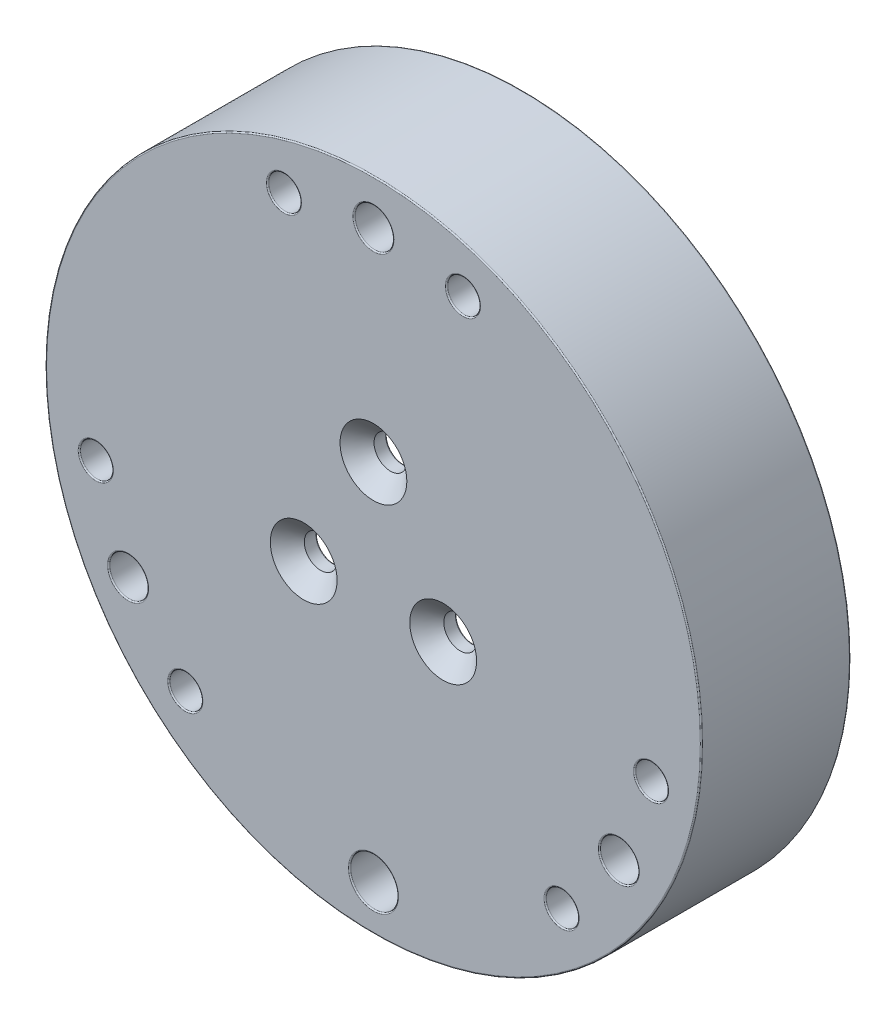
from build123d import *

# Parameters (mm, degrees)
CROQUIS1_R                                           = 55
CROQUIS1_R_2                                         = 52.5
SALIENTE_EXTRUIR1_DEPTH                              = 20
CROQUIS2_R                                           = 55
SALIENTE_EXTRUIR2_DEPTH                              = 5
REFRENTADO_PARA_TORNILLO_TAP_N_CON_CABEZ_D           = 5.5
REFRENTADO_PARA_TORNILLO_TAP_N_CON_CABEZ_CSINK_D     = 11.2
REFRENTADO_PARA_TORNILLO_TAP_N_CON_CABEZ_CSINK_ANGLE = 90
SALIENTE_EXTRUIR8_DEPTH                              = 10
CROQUIS12_R                                          = 3.25
CROQUIS12_R_2                                        = 4
CORTAR_EXTRUIR4_DEPTH                                = 10
CROQUIS16_R                                          = 2.75
CORTAR_EXTRUIR7_DEPTH                                = 5
REDONDEO1_R                                          = 0.2


with BuildPart() as part:
    # Croquis1 → Saliente-Extruir1 (new body)
    with BuildSketch(Plane.XY):
        Circle(CROQUIS1_R)
        Circle(CROQUIS1_R_2, mode=Mode.SUBTRACT)
    extrude(amount=SALIENTE_EXTRUIR1_DEPTH)

    # Croquis2 → Saliente-Extruir2 (add)
    with BuildSketch(Plane.XY.offset(20)):
        Circle(CROQUIS2_R)
    extrude(amount=SALIENTE_EXTRUIR2_DEPTH)

    # Refrentado para tornillo tapón con cabeza plana de clavija de M51 (through all)
    with Locations(Plane.XY.offset(25)):
        with Locations((0, 13.5), (-11.691342951, -6.75), (11.691342951, -6.75)):
            CounterSinkHole(REFRENTADO_PARA_TORNILLO_TAP_N_CON_CABEZ_D / 2, REFRENTADO_PARA_TORNILLO_TAP_N_CON_CABEZ_CSINK_D / 2, counter_sink_angle=REFRENTADO_PARA_TORNILLO_TAP_N_CON_CABEZ_CSINK_ANGLE)

    # Croquis10 → Saliente-Extruir8 (add)
    with BuildSketch(Plane(origin=(0, 0, 20), x_dir=(-1, 0, 0), z_dir=(0, 0, -1))):
        with BuildLine():
            Line((-3.5, 45), (-3.5, 51))
            ThreePointArc((-3.5, 51), (0, 54.5), (3.5, 51))
            Line((3.5, 51), (3.5, 45))
            ThreePointArc((3.5, 45), (0, 41.5), (-3.5, 45))
        make_face()
        with BuildLine():
            Line((40.72114317, -19.468911087), (45.917295593, -22.468911087))
            ThreePointArc((45.917295593, -22.468911087), (47.198384506, -27.25), (42.417295593, -28.531088913))
            Line((42.417295593, -28.531088913), (37.22114317, -25.531088913))
            ThreePointArc((37.22114317, -25.531088913), (35.940054257, -20.75), (40.72114317, -19.468911087))
        make_face()
        with BuildLine():
            Line((-37.22114317, -25.531088913), (-42.417295593, -28.531088913))
            ThreePointArc((-42.417295593, -28.531088913), (-47.198384506, -27.25), (-45.917295593, -22.468911087))
            Line((-45.917295593, -22.468911087), (-40.72114317, -19.468911087))
            ThreePointArc((-40.72114317, -19.468911087), (-35.940054257, -20.75), (-37.22114317, -25.531088913))
        make_face()
        with BuildLine():
            Line((-4.5, -50.030679936), (-4.5, -38.370856831))
            ThreePointArc((-4.5, -38.370856831), (0, -33.870856831), (4.5, -38.370856831))
            Line((4.5, -38.370856831), (4.5, -50.030679936))
            ThreePointArc((4.5, -50.030679936), (0, -54.530679936), (-4.5, -50.030679936))
        make_face()
    extrude(amount=SALIENTE_EXTRUIR8_DEPTH)

    # Croquis12 → Cortar-Extruir4 (cut)
    with BuildSketch(Plane.XY.offset(25)):
        with Locations((0, 47.5)):
            Circle(CROQUIS12_R)
        with Locations((41.13620668, -23.75)):
            Circle(CROQUIS12_R)
        with Locations((-41.13620668, -23.75)):
            Circle(CROQUIS12_R)
        with Locations((0, -47.5)):
            Circle(CROQUIS12_R_2)
    extrude(amount=-CORTAR_EXTRUIR4_DEPTH, mode=Mode.SUBTRACT)

    # Croquis16 → Cortar-Extruir7 (cut)
    with BuildSketch(Plane.XY.offset(25)):
        with Locations((-15.003552118, 45.088897544)):
            Circle(CROQUIS16_R)
        with Locations((15.003552118, 45.088897544)):
            Circle(CROQUIS16_R)
        with Locations((46.549906761, -9.55099149)):
            Circle(CROQUIS16_R)
        with Locations((31.546354642, -35.537906053)):
            Circle(CROQUIS16_R)
        with Locations((-31.546354642, -35.537906053)):
            Circle(CROQUIS16_R)
        with Locations((-46.549906761, -9.55099149)):
            Circle(CROQUIS16_R)
    extrude(amount=-CORTAR_EXTRUIR7_DEPTH, mode=Mode.SUBTRACT)

    # Redondeo1
    redondeo1_edges = [part.edges().sort_by_distance(p)[0] for p in [
        (-44.38620668, -23.75, 25),
        (37.88620668, -23.75, 15),
        (37.88620668, -23.75, 25),
        (-3.25, 47.5, 15),
        (-3.25, 47.5, 25),
        (-4, -47.5, 15),
        (-4, -47.5, 25),
        (-17.753552118, 45.088897544, 20),
        (-17.753552118, 45.088897544, 25),
        (12.253552118, 45.088897544, 20),
        (12.253552118, 45.088897544, 25),
        (43.799906761, -9.55099149, 20),
        (43.799906761, -9.55099149, 25),
        (28.796354642, -35.537906053, 20),
        (28.796354642, -35.537906053, 25),
        (-34.296354642, -35.537906053, 20),
        (-34.296354642, -35.537906053, 25),
        (-49.299906761, -9.55099149, 20),
        (-49.299906761, -9.55099149, 25),
        (-55, 0, 0),
        (14.441342951, -6.75, 20),
        (-8.941342951, -6.75, 20),
        (2.75, 13.5, 20),
        (-45.466333699, 26.25, 20),
        (3.425953357, 51.716130991, 20),
        (0, 41.5, 20),
        (-3.5, 48, 20),
        (-3.425953357, 51.716130991, 20),
        (3.5, 48, 10),
        (-3.425953357, 51.716130991, 10),
        (3.425953357, 51.716130991, 10),
        (0, 41.5, 10),
        (-3.5, 48, 10),
        (3.5, 48, 20),
        (-52.5, 0, 0),
        (38.240127433, 35.9714144, 20),
        (43.074506545, -28.825028135, 20),
        (35.940054257, -20.75, 20),
        (43.319219382, -20.968911087, 20),
        (46.500459902, -22.891102856, 20),
        (39.819219382, -27.031088913, 10),
        (46.500459902, -22.891102856, 10),
        (43.074506545, -28.825028135, 10),
        (35.940054257, -20.75, 10),
        (43.319219382, -20.968911087, 10),
        (39.819219382, -27.031088913, 20),
        (-26.529062355, -45.304071015, 20),
        (-46.500459902, -22.891102856, 20),
        (-35.940054257, -20.75, 20),
        (-39.819219382, -27.031088913, 20),
        (-43.074506545, -28.825028135, 20),
        (-43.319219382, -20.968911087, 10),
        (-43.074506545, -28.825028135, 10),
        (-46.500459902, -22.891102856, 10),
        (-35.940054257, -20.75, 10),
        (-39.819219382, -27.031088913, 10),
        (-43.319219382, -20.968911087, 20),
        (26.529062355, -45.304071015, 20),
        (-4.334740239, -51.238995731, 20),
        (4.5, -44.200768383, 20),
        (4.334740239, -51.238995731, 20),
        (-4.5, -44.200768383, 20),
        (0, -33.870856831, 20),
        (4.5, -44.200768383, 10),
        (4.334740239, -51.238995731, 10),
        (-4.334740239, -51.238995731, 10),
        (-4.5, -44.200768383, 10),
        (0, -33.870856831, 10),
        (-55, 0, 25),
    ]]
    fillet(redondeo1_edges, radius=REDONDEO1_R)


solid = part.part
